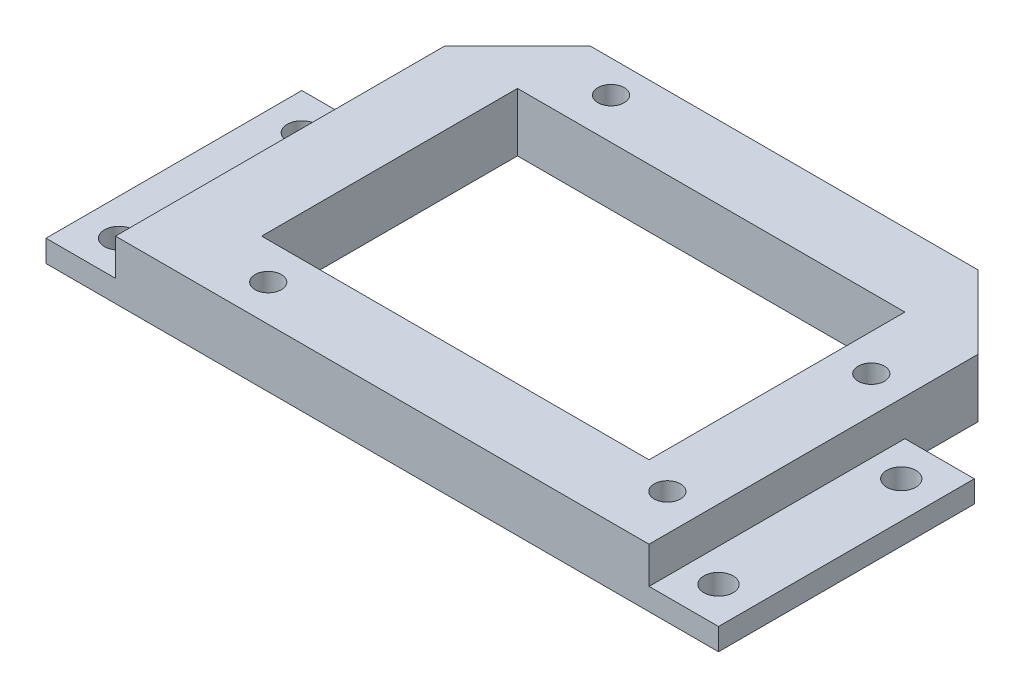
from build123d import *

# Parameters (mm, degrees)
SKETCH1_W                = 73
SKETCH1_H                = 35
BOSS_EXTRUDE1_DEPTH      = 5
SKETCH2_W                = 92
SKETCH2_H                = 35
BOSS_EXTRUDE2_DEPTH      = 3
M3_CLEARANCE_HOLE1_D     = 4
M3_CLEARANCE_HOLE1_DEPTH = 10
M3_CLEARANCE_HOLE1_TIP   = 1.201721238
SKETCH9_W                = 73
SKETCH9_H                = 8
BOSS_EXTRUDE3_DEPTH      = 20
M3_CLEARANCE_HOLE3_D     = 3.6
M3_CLEARANCE_HOLE3_DEPTH = 10
M3_CLEARANCE_HOLE3_TIP   = 1.081549114
SKETCH12_W               = 53
SKETCH12_H               = 35
CUT_EXTRUDE1_DEPTH       = 9
CHAMFER1_SIZE            = 10


with BuildPart() as part:
    # Sketch1 → Boss-Extrude1 (new body)
    with BuildSketch(Plane(origin=(0, 0, 0), x_dir=(1, 0, 0), z_dir=(0, 1, 0))):
        Rectangle(SKETCH1_W, SKETCH1_H)
    extrude(amount=BOSS_EXTRUDE1_DEPTH)

    # Sketch2 → Boss-Extrude2 (add)
    with BuildSketch(Plane.XZ):
        Rectangle(SKETCH2_W, SKETCH2_H)
    extrude(amount=BOSS_EXTRUDE2_DEPTH)

    # M3 Clearance Hole1
    with Locations(Plane(origin=(0, 0, 0), x_dir=(1, 0, 0), z_dir=(0, 1, 0))):
        with Locations((-41, 12.5), (-41, -12.5), (41, 12.5), (41, -12.5)):
            Hole(M3_CLEARANCE_HOLE1_D / 2, depth=M3_CLEARANCE_HOLE1_DEPTH)
            with Locations((0, 0, -(M3_CLEARANCE_HOLE1_DEPTH + M3_CLEARANCE_HOLE1_TIP / 2))):  # 118° drill point
                Cone(0, M3_CLEARANCE_HOLE1_D / 2, M3_CLEARANCE_HOLE1_TIP, mode=Mode.SUBTRACT)

    # Sketch9 → Boss-Extrude3 (add)
    with BuildSketch(Plane(origin=(0, 0, -17.5), x_dir=(-1, 0, 0), z_dir=(0, 0, -1))):
        with Locations((0, 1)):
            Rectangle(SKETCH9_W, SKETCH9_H)
    extrude(amount=BOSS_EXTRUDE3_DEPTH)

    # M3 Clearance Hole3
    with Locations(Plane(origin=(0, 5, 0), x_dir=(1, 0, 0), z_dir=(0, 1, 0))):
        with Locations((-20.6, -12.5), (-19.3, 33.1), (31.5, -10), (31.5, 17.9)):
            Hole(M3_CLEARANCE_HOLE3_D / 2, depth=M3_CLEARANCE_HOLE3_DEPTH)
            with Locations((0, 0, -(M3_CLEARANCE_HOLE3_DEPTH + M3_CLEARANCE_HOLE3_TIP / 2))):  # 118° drill point
                Cone(0, M3_CLEARANCE_HOLE3_D / 2, M3_CLEARANCE_HOLE3_TIP, mode=Mode.SUBTRACT)

    # Sketch12 → Cut-Extrude1 (cut, through all)
    with BuildSketch(Plane(origin=(0, 5, 0), x_dir=(1, 0, 0), z_dir=(0, 1, 0))):
        with Locations((0, 10)):
            Rectangle(SKETCH12_W, SKETCH12_H)
    extrude(amount=-CUT_EXTRUDE1_DEPTH, mode=Mode.SUBTRACT)

    # Chamfer1
    chamfer1_edges = [part.edges().sort_by_distance(p)[0] for p in [
        (36.5, 1, -37.5),
        (-36.5, 1, -37.5),
    ]]
    chamfer(chamfer1_edges, length=CHAMFER1_SIZE)


solid = part.part
